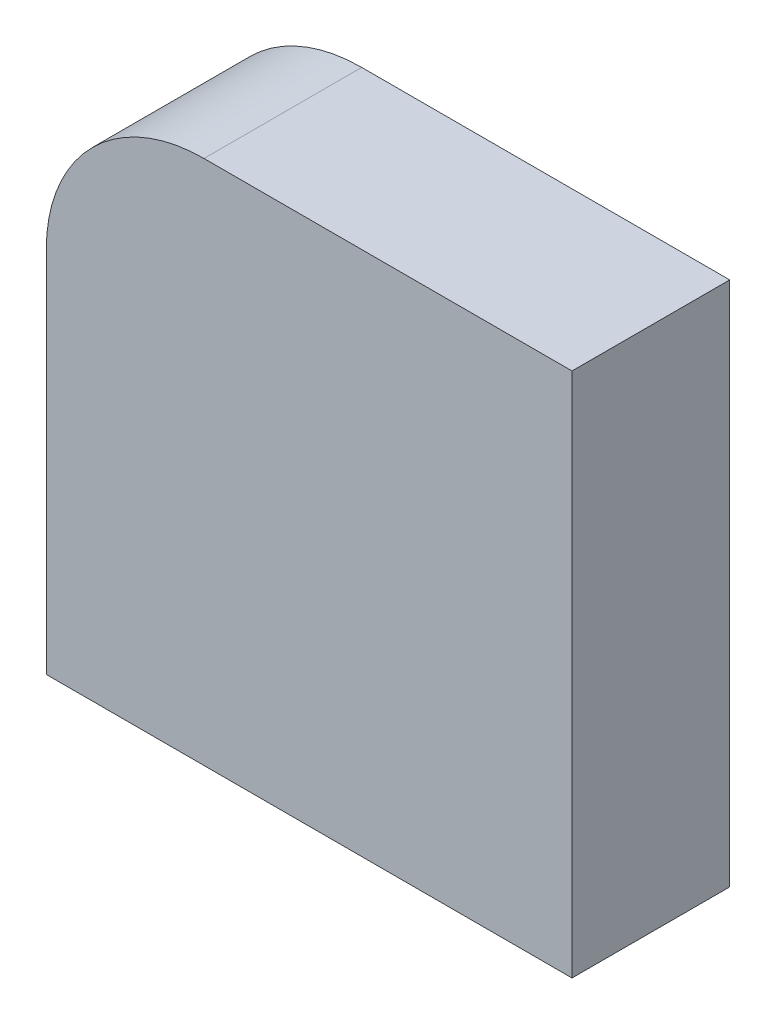
from build123d import *

# Parameters (mm, degrees)
BOSS_EXTRUDE1_DEPTH = 76.2


with BuildPart() as part:
    # Sketch1 → Boss-Extrude1 (new body)
    with BuildSketch(Plane.XY):
        with BuildLine():
            Line((0, 0), (0, 254))
            Line((0, 254), (-177.8, 254))
            ThreePointArc((-177.8, 254), (-231.681536726, 231.681536726), (-254, 177.8))
            Line((-254, 177.8), (-254, 0))
            Line((-254, 0), (0, 0))
        make_face()
    extrude(amount=-BOSS_EXTRUDE1_DEPTH)


solid = part.part
